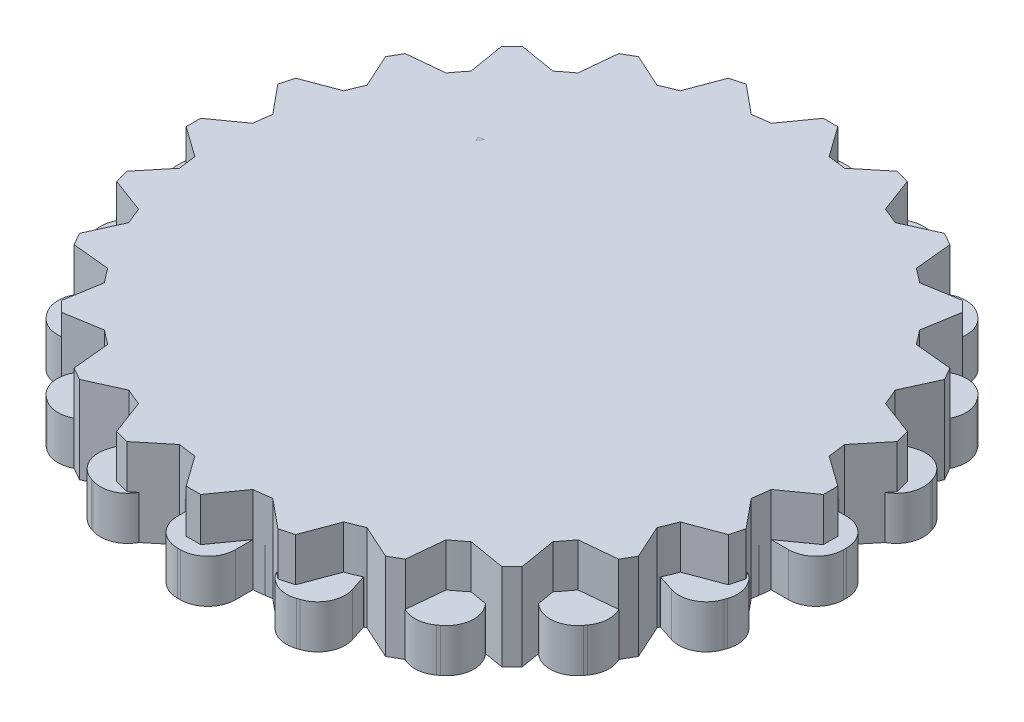
from build123d import *

# Parameters (mm, degrees)
BOSS_EXTRUDE3_DEPTH = 3
BOSS_EXTRUDE5_DEPTH = 6
SKETCH1_W           = 5
SKETCH1_H           = 3
BOSS_EXTRUDE6_DEPTH = 6


with BuildPart() as part:
    # Sketch2 → Boss-Extrude3 (new body)
    with BuildSketch(Plane(origin=(0, 0, 0), x_dir=(1, 0, 0), z_dir=(0, 1, 0))):
        with BuildLine():
            Line((-23, -0.1), (-23, 0.1))
            ThreePointArc((-23, 0.1), (-22.443502884, 1.443502884), (-21.1, 2))
            Line((-21.1, 2), (-19.899748742, 2))
            ThreePointArc((-19.899748742, 2), (-19.753766812, 3.128689301), (-19.543819703, 4.247247513))
            Line((-19.543819703, 4.247247513), (-20.685326483, 4.618145549))
            ThreePointArc((-20.685326483, 4.618145549), (-21.791106589, 5.56257098), (-21.905201574, 7.012285219))
            Line((-21.905201574, 7.012285219), (-21.843398175, 7.202496522))
            ThreePointArc((-21.843398175, 7.202496522), (-20.898972744, 8.308276629), (-19.449258505, 8.422371614))
            Line((-19.449258505, 8.422371614), (-18.307751725, 8.051473578))
            ThreePointArc((-18.307751725, 8.051473578), (-17.820130484, 9.079809995), (-17.274805421, 10.078744846))
            Line((-17.274805421, 10.078744846), (-18.245829086, 10.784234835))
            ThreePointArc((-18.245829086, 10.784234835), (-19.005644954, 12.02414164), (-18.666169396, 13.438159103))
            Line((-18.666169396, 13.438159103), (-18.548612345, 13.599962502))
            ThreePointArc((-18.548612345, 13.599962502), (-17.30870554, 14.35977837), (-15.894688077, 14.020302812))
            Line((-15.894688077, 14.020302812), (-14.923664412, 13.314812824))
            ThreePointArc((-14.923664412, 13.314812824), (-14.142135624, 14.142135624), (-13.314812824, 14.923664412))
            Line((-13.314812824, 14.923664412), (-14.020302812, 15.894688077))
            ThreePointArc((-14.020302812, 15.894688077), (-14.35977837, 17.30870554), (-13.599962502, 18.548612345))
            Line((-13.599962502, 18.548612345), (-13.438159103, 18.666169396))
            ThreePointArc((-13.438159103, 18.666169396), (-12.02414164, 19.005644954), (-10.784234835, 18.245829086))
            Line((-10.784234835, 18.245829086), (-10.078744846, 17.274805421))
            ThreePointArc((-10.078744846, 17.274805421), (-9.079809995, 17.820130484), (-8.051473578, 18.307751725))
            Line((-8.051473578, 18.307751725), (-8.422371614, 19.449258505))
            ThreePointArc((-8.422371614, 19.449258505), (-8.308276629, 20.898972744), (-7.202496522, 21.843398175))
            Line((-7.202496522, 21.843398175), (-7.012285219, 21.905201574))
            ThreePointArc((-7.012285219, 21.905201574), (-5.56257098, 21.791106589), (-4.618145549, 20.685326483))
            Line((-4.618145549, 20.685326483), (-4.247247513, 19.543819703))
            ThreePointArc((-4.247247513, 19.543819703), (-3.128689301, 19.753766812), (-2, 19.899748742))
            Line((-2, 19.899748742), (-2, 21.1))
            ThreePointArc((-2, 21.1), (-1.443502884, 22.443502884), (-0.1, 23))
            Line((-0.1, 23), (0.1, 23))
            ThreePointArc((0.1, 23), (1.443502884, 22.443502884), (2, 21.1))
            Line((2, 21.1), (2, 19.899748742))
            ThreePointArc((2, 19.899748742), (3.128689301, 19.753766812), (4.247247513, 19.543819703))
            Line((4.247247513, 19.543819703), (4.618145549, 20.685326483))
            ThreePointArc((4.618145549, 20.685326483), (5.56257098, 21.791106589), (7.012285219, 21.905201574))
            Line((7.012285219, 21.905201574), (7.202496522, 21.843398175))
            ThreePointArc((7.202496522, 21.843398175), (8.308276629, 20.898972744), (8.422371614, 19.449258505))
            Line((8.422371614, 19.449258505), (8.051473578, 18.307751725))
            ThreePointArc((8.051473578, 18.307751725), (9.079809995, 17.820130484), (10.078744846, 17.274805421))
            Line((10.078744846, 17.274805421), (10.784234835, 18.245829086))
            ThreePointArc((10.784234835, 18.245829086), (12.02414164, 19.005644954), (13.438159103, 18.666169396))
            Line((13.438159103, 18.666169396), (13.599962502, 18.548612345))
            ThreePointArc((13.599962502, 18.548612345), (14.35977837, 17.30870554), (14.020302812, 15.894688077))
            Line((14.020302812, 15.894688077), (13.314812824, 14.923664412))
            ThreePointArc((13.314812824, 14.923664412), (14.142135624, 14.142135624), (14.923664412, 13.314812824))
            Line((14.923664412, 13.314812824), (15.894688077, 14.020302812))
            ThreePointArc((15.894688077, 14.020302812), (17.30870554, 14.35977837), (18.548612345, 13.599962502))
            Line((18.548612345, 13.599962502), (18.666169396, 13.438159103))
            ThreePointArc((18.666169396, 13.438159103), (19.005644954, 12.02414164), (18.245829086, 10.784234835))
            Line((18.245829086, 10.784234835), (17.274805421, 10.078744846))
            ThreePointArc((17.274805421, 10.078744846), (17.820130484, 9.079809995), (18.307751725, 8.051473578))
            Line((18.307751725, 8.051473578), (19.449258505, 8.422371614))
            ThreePointArc((19.449258505, 8.422371614), (20.898972744, 8.308276629), (21.843398175, 7.202496522))
            Line((21.843398175, 7.202496522), (21.905201574, 7.012285219))
            ThreePointArc((21.905201574, 7.012285219), (21.791106589, 5.56257098), (20.685326483, 4.618145549))
            Line((20.685326483, 4.618145549), (19.543819703, 4.247247513))
            ThreePointArc((19.543819703, 4.247247513), (19.753766812, 3.128689301), (19.899748742, 2))
            Line((19.899748742, 2), (21.1, 2))
            ThreePointArc((21.1, 2), (22.443502884, 1.443502884), (23, 0.1))
            Line((23, 0.1), (23, -0.1))
            ThreePointArc((23, -0.1), (22.443502884, -1.443502884), (21.1, -2))
            Line((21.1, -2), (19.899748742, -2))
            ThreePointArc((19.899748742, -2), (19.753766812, -3.128689301), (19.543819703, -4.247247513))
            Line((19.543819703, -4.247247513), (20.685326483, -4.618145549))
            ThreePointArc((20.685326483, -4.618145549), (21.791106589, -5.56257098), (21.905201574, -7.012285219))
            Line((21.905201574, -7.012285219), (21.843398175, -7.202496522))
            ThreePointArc((21.843398175, -7.202496522), (20.898972744, -8.308276629), (19.449258505, -8.422371614))
            Line((19.449258505, -8.422371614), (18.307751725, -8.051473578))
            ThreePointArc((18.307751725, -8.051473578), (17.820130484, -9.079809995), (17.274805421, -10.078744846))
            Line((17.274805421, -10.078744846), (18.245829086, -10.784234835))
            ThreePointArc((18.245829086, -10.784234835), (19.005644954, -12.02414164), (18.666169396, -13.438159103))
            Line((18.666169396, -13.438159103), (18.548612345, -13.599962502))
            ThreePointArc((18.548612345, -13.599962502), (17.30870554, -14.35977837), (15.894688077, -14.020302812))
            Line((15.894688077, -14.020302812), (14.923664412, -13.314812824))
            ThreePointArc((14.923664412, -13.314812824), (14.142135624, -14.142135624), (13.314812824, -14.923664412))
            Line((13.314812824, -14.923664412), (14.020302812, -15.894688077))
            ThreePointArc((14.020302812, -15.894688077), (14.35977837, -17.30870554), (13.599962502, -18.548612345))
            Line((13.599962502, -18.548612345), (13.438159103, -18.666169396))
            ThreePointArc((13.438159103, -18.666169396), (12.02414164, -19.005644954), (10.784234835, -18.245829086))
            Line((10.784234835, -18.245829086), (10.078744846, -17.274805421))
            ThreePointArc((10.078744846, -17.274805421), (9.079809995, -17.820130484), (8.051473578, -18.307751725))
            Line((8.051473578, -18.307751725), (8.422371614, -19.449258505))
            ThreePointArc((8.422371614, -19.449258505), (8.308276629, -20.898972744), (7.202496522, -21.843398175))
            Line((7.202496522, -21.843398175), (7.012285219, -21.905201574))
            ThreePointArc((7.012285219, -21.905201574), (5.56257098, -21.791106589), (4.618145549, -20.685326483))
            Line((4.618145549, -20.685326483), (4.247247513, -19.543819703))
            ThreePointArc((4.247247513, -19.543819703), (3.128689301, -19.753766812), (2, -19.899748742))
            Line((2, -19.899748742), (2, -21.1))
            ThreePointArc((2, -21.1), (1.443502884, -22.443502884), (0.1, -23))
            Line((0.1, -23), (-0.1, -23))
            ThreePointArc((-0.1, -23), (-1.443502884, -22.443502884), (-2, -21.1))
            Line((-2, -21.1), (-2, -19.899748742))
            ThreePointArc((-2, -19.899748742), (-3.128689301, -19.753766812), (-4.247247513, -19.543819703))
            Line((-4.247247513, -19.543819703), (-4.618145549, -20.685326483))
            ThreePointArc((-4.618145549, -20.685326483), (-5.56257098, -21.791106589), (-7.012285219, -21.905201574))
            Line((-7.012285219, -21.905201574), (-7.202496522, -21.843398175))
            ThreePointArc((-7.202496522, -21.843398175), (-8.308276629, -20.898972744), (-8.422371614, -19.449258505))
            Line((-8.422371614, -19.449258505), (-8.051473578, -18.307751725))
            ThreePointArc((-8.051473578, -18.307751725), (-9.079809995, -17.820130484), (-10.078744846, -17.274805421))
            Line((-10.078744846, -17.274805421), (-10.784234835, -18.245829086))
            ThreePointArc((-10.784234835, -18.245829086), (-12.02414164, -19.005644954), (-13.438159103, -18.666169396))
            Line((-13.438159103, -18.666169396), (-13.599962502, -18.548612345))
            ThreePointArc((-13.599962502, -18.548612345), (-14.35977837, -17.30870554), (-14.020302812, -15.894688077))
            Line((-14.020302812, -15.894688077), (-13.314812824, -14.923664412))
            ThreePointArc((-13.314812824, -14.923664412), (-14.142135624, -14.142135624), (-14.923664412, -13.314812824))
            Line((-14.923664412, -13.314812824), (-15.894688077, -14.020302812))
            ThreePointArc((-15.894688077, -14.020302812), (-17.30870554, -14.35977837), (-18.548612345, -13.599962502))
            Line((-18.548612345, -13.599962502), (-18.666169396, -13.438159103))
            ThreePointArc((-18.666169396, -13.438159103), (-19.005644954, -12.02414164), (-18.245829086, -10.784234835))
            Line((-18.245829086, -10.784234835), (-17.274805421, -10.078744846))
            ThreePointArc((-17.274805421, -10.078744846), (-17.820130484, -9.079809995), (-18.307751725, -8.051473578))
            Line((-18.307751725, -8.051473578), (-19.449258505, -8.422371614))
            ThreePointArc((-19.449258505, -8.422371614), (-20.898972744, -8.308276629), (-21.843398175, -7.202496522))
            Line((-21.843398175, -7.202496522), (-21.905201574, -7.012285219))
            ThreePointArc((-21.905201574, -7.012285219), (-21.791106589, -5.56257098), (-20.685326483, -4.618145549))
            Line((-20.685326483, -4.618145549), (-19.543819703, -4.247247513))
            ThreePointArc((-19.543819703, -4.247247513), (-19.753766812, -3.128689301), (-19.899748742, -2))
            Line((-19.899748742, -2), (-21.1, -2))
            ThreePointArc((-21.1, -2), (-22.443502884, -1.443502884), (-23, -0.1))
        make_face()
    extrude(amount=BOSS_EXTRUDE3_DEPTH)


with BuildPart() as body_2:
    # Sketch3 → Boss-Extrude5 (new body)
    with BuildSketch(Plane(origin=(0, 0, 0), x_dir=(1, 0, 0), z_dir=(0, 1, 0))):
        with BuildLine():
            Line((-22, 0.5), (-22, 0))
            Line((-22, 0), (22, 0))
            Line((22, 0), (22, 0.5))
            Line((22, 0.5), (19.899748742, 2))
            ThreePointArc((19.899748742, 2), (19.828897227, 2.610523844), (19.739319337, 3.218582315))
            Line((19.739319337, 3.218582315), (21.379777701, 5.211056079))
            Line((21.379777701, 5.211056079), (21.120958656, 6.176981905))
            Line((21.120958656, 6.176981905), (18.704043156, 7.08228562))
            ThreePointArc((18.704043156, 7.08228562), (18.47759065, 7.653668647), (18.23368794, 8.217823563))
            Line((18.23368794, 8.217823563), (19.302558883, 10.566987298))
            Line((19.302558883, 10.566987298), (18.802558883, 11.433012702))
            Line((18.802558883, 11.433012702), (16.23368794, 11.681925179))
            ThreePointArc((16.23368794, 11.681925179), (15.867066806, 12.17522858), (15.485460842, 12.657033717))
            Line((15.485460842, 12.657033717), (15.909902577, 15.202795796))
            Line((15.909902577, 15.202795796), (15.202795796, 15.909902577))
            Line((15.202795796, 15.909902577), (12.657033717, 15.485460842))
            ThreePointArc((12.657033717, 15.485460842), (12.17522858, 15.867066806), (11.681925179, 16.23368794))
            Line((11.681925179, 16.23368794), (11.433012702, 18.802558883))
            Line((11.433012702, 18.802558883), (10.566987298, 19.302558883))
            Line((10.566987298, 19.302558883), (8.217823563, 18.23368794))
            ThreePointArc((8.217823563, 18.23368794), (7.653668647, 18.47759065), (7.08228562, 18.704043156))
            Line((7.08228562, 18.704043156), (6.176981905, 21.120958656))
            Line((6.176981905, 21.120958656), (5.211056079, 21.379777701))
            Line((5.211056079, 21.379777701), (3.218582315, 19.739319337))
            ThreePointArc((3.218582315, 19.739319337), (2.610523844, 19.828897227), (2, 19.899748742))
            Line((2, 19.899748742), (0.5, 22))
            Line((0.5, 22), (-0.5, 22))
            Line((-0.5, 22), (-2, 19.899748742))
            ThreePointArc((-2, 19.899748742), (-2.610523844, 19.828897227), (-3.218582315, 19.739319337))
            Line((-3.218582315, 19.739319337), (-5.211056079, 21.379777701))
            Line((-5.211056079, 21.379777701), (-6.176981905, 21.120958656))
            Line((-6.176981905, 21.120958656), (-7.08228562, 18.704043156))
            ThreePointArc((-7.08228562, 18.704043156), (-7.653668647, 18.47759065), (-8.217823563, 18.23368794))
            Line((-8.217823563, 18.23368794), (-10.566987298, 19.302558883))
            Line((-10.566987298, 19.302558883), (-11.433012702, 18.802558883))
            Line((-11.433012702, 18.802558883), (-11.681925179, 16.23368794))
            ThreePointArc((-11.681925179, 16.23368794), (-12.17522858, 15.867066806), (-12.657033717, 15.485460842))
            Line((-12.657033717, 15.485460842), (-15.202795796, 15.909902577))
            Line((-15.202795796, 15.909902577), (-15.909902577, 15.202795796))
            Line((-15.909902577, 15.202795796), (-15.485460842, 12.657033717))
            ThreePointArc((-15.485460842, 12.657033717), (-15.867066806, 12.17522858), (-16.23368794, 11.681925179))
            Line((-16.23368794, 11.681925179), (-18.802558883, 11.433012702))
            Line((-18.802558883, 11.433012702), (-19.302558883, 10.566987298))
            Line((-19.302558883, 10.566987298), (-18.23368794, 8.217823563))
            ThreePointArc((-18.23368794, 8.217823563), (-18.47759065, 7.653668647), (-18.704043156, 7.08228562))
            Line((-18.704043156, 7.08228562), (-21.120958656, 6.176981905))
            Line((-21.120958656, 6.176981905), (-21.379777701, 5.211056079))
            Line((-21.379777701, 5.211056079), (-19.739319337, 3.218582315))
            ThreePointArc((-19.739319337, 3.218582315), (-19.828897227, 2.610523844), (-19.899748742, 2))
            Line((-19.899748742, 2), (-22, 0.5))
        make_face()
        with BuildLine():
            Line((22, 0), (-22, 0))
            Line((-22, 0), (-22, -0.5))
            Line((-22, -0.5), (-19.899748742, -2))
            ThreePointArc((-19.899748742, -2), (-19.828897227, -2.610523844), (-19.739319337, -3.218582315))
            Line((-19.739319337, -3.218582315), (-21.379777701, -5.211056079))
            Line((-21.379777701, -5.211056079), (-21.120958656, -6.176981905))
            Line((-21.120958656, -6.176981905), (-18.704043156, -7.08228562))
            ThreePointArc((-18.704043156, -7.08228562), (-18.47759065, -7.653668647), (-18.23368794, -8.217823563))
            Line((-18.23368794, -8.217823563), (-19.302558883, -10.566987298))
            Line((-19.302558883, -10.566987298), (-18.802558883, -11.433012702))
            Line((-18.802558883, -11.433012702), (-16.23368794, -11.681925179))
            ThreePointArc((-16.23368794, -11.681925179), (-15.867066806, -12.17522858), (-15.485460842, -12.657033717))
            Line((-15.485460842, -12.657033717), (-15.909902577, -15.202795796))
            Line((-15.909902577, -15.202795796), (-15.202795796, -15.909902577))
            Line((-15.202795796, -15.909902577), (-12.657033717, -15.485460842))
            ThreePointArc((-12.657033717, -15.485460842), (-12.17522858, -15.867066806), (-11.681925179, -16.23368794))
            Line((-11.681925179, -16.23368794), (-11.433012702, -18.802558883))
            Line((-11.433012702, -18.802558883), (-10.566987298, -19.302558883))
            Line((-10.566987298, -19.302558883), (-8.217823563, -18.23368794))
            ThreePointArc((-8.217823563, -18.23368794), (-7.653668647, -18.47759065), (-7.08228562, -18.704043156))
            Line((-7.08228562, -18.704043156), (-6.176981905, -21.120958656))
            Line((-6.176981905, -21.120958656), (-5.211056079, -21.379777701))
            Line((-5.211056079, -21.379777701), (-3.218582315, -19.739319337))
            ThreePointArc((-3.218582315, -19.739319337), (-2.610523844, -19.828897227), (-2, -19.899748742))
            Line((-2, -19.899748742), (-0.5, -22))
            Line((-0.5, -22), (0.5, -22))
            Line((0.5, -22), (2, -19.899748742))
            ThreePointArc((2, -19.899748742), (2.610523844, -19.828897227), (3.218582315, -19.739319337))
            Line((3.218582315, -19.739319337), (5.211056079, -21.379777701))
            Line((5.211056079, -21.379777701), (6.176981905, -21.120958656))
            Line((6.176981905, -21.120958656), (7.08228562, -18.704043156))
            ThreePointArc((7.08228562, -18.704043156), (7.653668647, -18.47759065), (8.217823563, -18.23368794))
            Line((8.217823563, -18.23368794), (10.566987298, -19.302558883))
            Line((10.566987298, -19.302558883), (11.433012702, -18.802558883))
            Line((11.433012702, -18.802558883), (11.681925179, -16.23368794))
            ThreePointArc((11.681925179, -16.23368794), (12.17522858, -15.867066806), (12.657033717, -15.485460842))
            Line((12.657033717, -15.485460842), (15.202795796, -15.909902577))
            Line((15.202795796, -15.909902577), (15.909902577, -15.202795796))
            Line((15.909902577, -15.202795796), (15.485460842, -12.657033717))
            ThreePointArc((15.485460842, -12.657033717), (15.867066806, -12.17522858), (16.23368794, -11.681925179))
            Line((16.23368794, -11.681925179), (18.802558883, -11.433012702))
            Line((18.802558883, -11.433012702), (19.302558883, -10.566987298))
            Line((19.302558883, -10.566987298), (18.23368794, -8.217823563))
            ThreePointArc((18.23368794, -8.217823563), (18.47759065, -7.653668647), (18.704043156, -7.08228562))
            Line((18.704043156, -7.08228562), (21.120958656, -6.176981905))
            Line((21.120958656, -6.176981905), (21.379777701, -5.211056079))
            Line((21.379777701, -5.211056079), (19.739319337, -3.218582315))
            ThreePointArc((19.739319337, -3.218582315), (19.828897227, -2.610523844), (19.899748742, -2))
            Line((19.899748742, -2), (22, -0.5))
            Line((22, -0.5), (22, 0))
        make_face()
    extrude(amount=BOSS_EXTRUDE5_DEPTH)


with BuildPart() as body_3:
    # Sketch1 → Boss-Extrude6 (new body)
    with BuildSketch(Plane(origin=(0, 0, 0), x_dir=(1, 0, 0), z_dir=(0, 1, 0))):
        with BuildLine():
            Line((-1.142396869, 15.366895677), (-0.142396869, 15.366895677))
            Line((-0.142396869, 15.366895677), (1.357603131, 13.164854648))
            ThreePointArc((1.357603131, 13.164854648), (1.945793582, 13.026153939), (2.524531809, 12.852177051))
            Line((2.524531809, 12.852177051), (4.924590429, 14.009200522))
            Line((4.924590429, 14.009200522), (5.790615833, 13.509200522))
            Line((5.790615833, 13.509200522), (5.988633424, 10.852177051))
            ThreePointArc((5.988633424, 10.852177051), (6.428670943, 10.437963488), (6.842884505, 9.99792597))
            Line((6.842884505, 9.99792597), (9.499907976, 9.799908378))
            Line((9.499907976, 9.799908378), (9.999907976, 8.933882975))
            Line((9.999907976, 8.933882975), (8.842884505, 6.533824355))
            ThreePointArc((8.842884505, 6.533824355), (9.016861394, 5.955086128), (9.155562102, 5.366895677))
            Line((9.155562102, 5.366895677), (11.357603131, 3.866895677))
            Line((11.357603131, 3.866895677), (11.357603131, 2.866895677))
            Line((11.357603131, 2.866895677), (9.155562102, 1.366895677))
            ThreePointArc((9.155562102, 1.366895677), (9.016861394, 0.778705226), (8.842884505, 0.199966999))
            Line((8.842884505, 0.199966999), (9.999907976, -2.200091622))
            Line((9.999907976, -2.200091622), (9.499907976, -3.066117025))
            Line((9.499907976, -3.066117025), (6.842884505, -3.264134617))
            ThreePointArc((6.842884505, -3.264134617), (6.428670943, -3.704172135), (5.988633424, -4.118385698))
            Line((5.988633424, -4.118385698), (5.790615833, -6.775409169))
            Line((5.790615833, -6.775409169), (4.924590429, -7.275409169))
            Line((4.924590429, -7.275409169), (2.524531809, -6.118385698))
            ThreePointArc((2.524531809, -6.118385698), (1.945793582, -6.292362586), (1.357603131, -6.431063295))
            Line((1.357603131, -6.431063295), (-0.142396869, -8.633104323))
            Line((-0.142396869, -8.633104323), (-1.142396869, -8.633104323))
            Line((-1.142396869, -8.633104323), (-2.642396869, -6.431063295))
            ThreePointArc((-2.642396869, -6.431063295), (-3.23058732, -6.292362586), (-3.809325547, -6.118385698))
            Line((-3.809325547, -6.118385698), (-6.209384167, -7.275409169))
            Line((-6.209384167, -7.275409169), (-7.075409571, -6.775409169))
            Line((-7.075409571, -6.775409169), (-7.273427162, -4.118385698))
            ThreePointArc((-7.273427162, -4.118385698), (-7.713464681, -3.704172135), (-8.127678243, -3.264134617))
            Line((-8.127678243, -3.264134617), (-10.784701714, -3.066117025))
            Line((-10.784701714, -3.066117025), (-11.284701714, -2.200091622))
            Line((-11.284701714, -2.200091622), (-10.127678243, 0.199966999))
            ThreePointArc((-10.127678243, 0.199966999), (-10.301655132, 0.778705226), (-10.44035584, 1.366895677))
            Line((-10.44035584, 1.366895677), (-12.642396869, 2.866895677))
            Line((-12.642396869, 2.866895677), (-12.642396869, 3.866895677))
            Line((-12.642396869, 3.866895677), (-10.44035584, 5.366895677))
            ThreePointArc((-10.44035584, 5.366895677), (-10.301655132, 5.955086128), (-10.127678243, 6.533824355))
            Line((-10.127678243, 6.533824355), (-11.284701714, 8.933882975))
            Line((-11.284701714, 8.933882975), (-10.784701714, 9.799908378))
            Line((-10.784701714, 9.799908378), (-8.127678243, 9.99792597))
            ThreePointArc((-8.127678243, 9.99792597), (-7.713464681, 10.437963488), (-7.273427162, 10.852177051))
            Line((-7.273427162, 10.852177051), (-7.075409571, 13.509200522))
            Line((-7.075409571, 13.509200522), (-6.209384167, 14.009200522))
            Line((-6.209384167, 14.009200522), (-3.809325547, 12.852177051))
            ThreePointArc((-3.809325547, 12.852177051), (-3.23058732, 13.026153939), (-2.642396869, 13.164854648))
            Line((-2.642396869, 13.164854648), (-1.142396869, 15.366895677))
        make_face()
        with Locations((-0.642396869, 3.366895677)):
            Rectangle(SKETCH1_W, SKETCH1_H, mode=Mode.SUBTRACT)
    extrude(amount=BOSS_EXTRUDE6_DEPTH)


solid = Compound([part.part, body_2.part, body_3.part])
